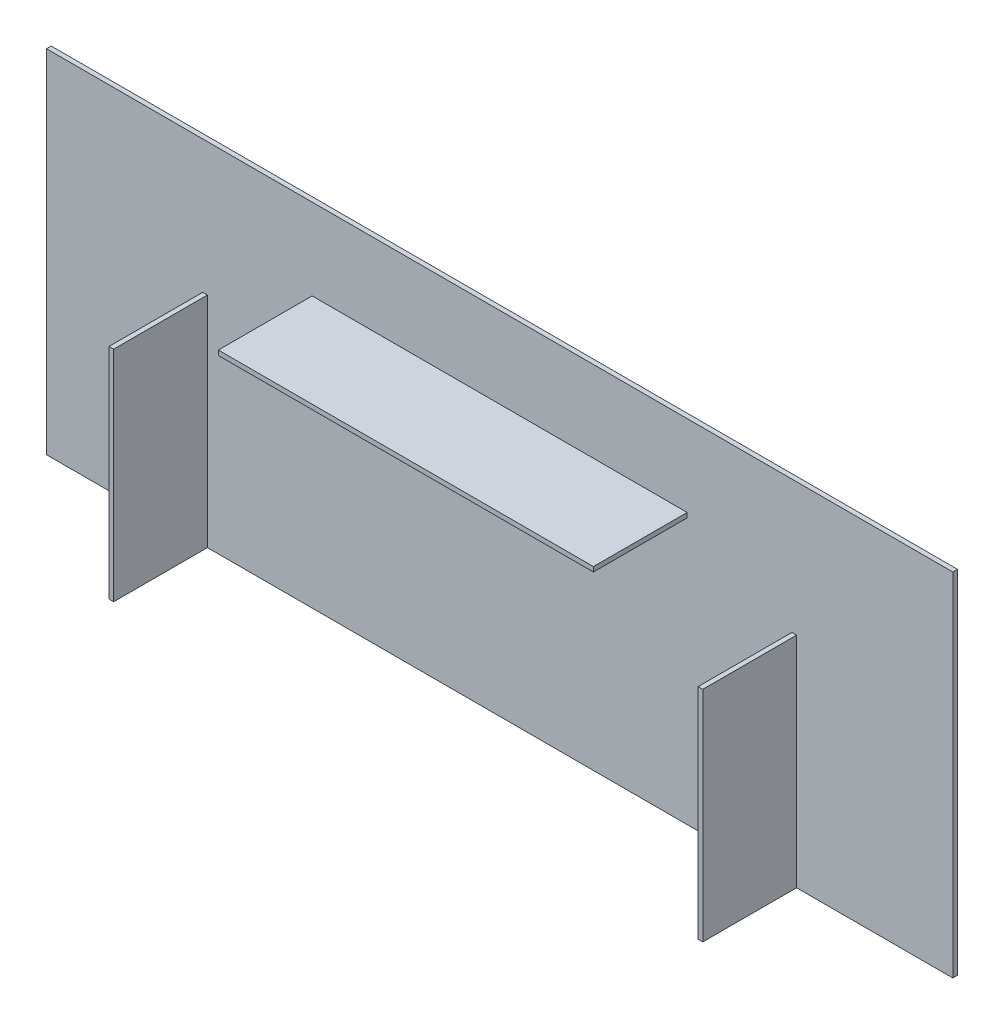
from build123d import *

# Parameters (mm, degrees)
SKETCH_1_W      = 290
SKETCH_1_H      = 112.5
EXTRUDE_1_DEPTH = 1.5
SKETCH_2_W      = 120
SKETCH_2_H      = 1.5
SKETCH_2_W_2    = 1.5
SKETCH_2_H_2    = 70
EXTRUDE_2_DEPTH = 30


with BuildPart() as part:
    # 草圖1 → 填料-伸長1 (new body)
    with BuildSketch(Plane.XY):
        with Locations((-32.068661972, 26.540492958)):
            Rectangle(SKETCH_1_W, SKETCH_1_H)
    extrude(amount=EXTRUDE_1_DEPTH)

    # 草圖2 → 填料-伸長2 (add)
    with BuildSketch(Plane.XY.offset(1.5)):
        with Locations((-32.068661972, 56.040492958)):
            Rectangle(SKETCH_2_W, SKETCH_2_H)
        with Locations((62.181338028, 5.290492958)):
            Rectangle(SKETCH_2_W_2, SKETCH_2_H_2)
        with Locations((-126.318661972, 5.290492958)):
            Rectangle(SKETCH_2_W_2, SKETCH_2_H_2)
    extrude(amount=EXTRUDE_2_DEPTH)


solid = part.part
